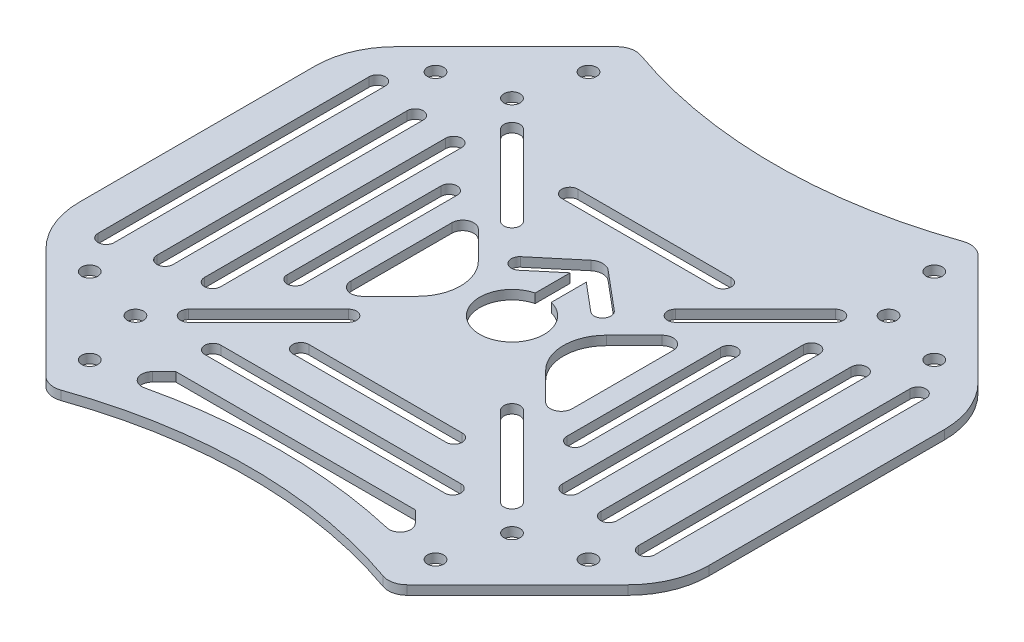
from build123d import *

# Parameters (mm, degrees)
SKETCH_1_R      = 1.5
EXTRUDE_1_DEPTH = 1.7
FILLET_1_R      = 3.5
FILLET_2_R      = 15


with BuildPart() as part:
    # 草圖1 → 填料-伸長1 (new body)
    with BuildSketch(Plane(origin=(0, 0, 0), x_dir=(1, 0, 0), z_dir=(0, 1, 0))):
        with BuildLine():
            Line((-31.988251141, -54.632329554), (-58.5, -28.120580695))
            Line((-58.5, -28.120580695), (-58.5, 28.120580695))
            Line((-58.5, 28.120580695), (-31.988251141, 54.632329554))
            ThreePointArc((-31.988251141, 54.632329554), (0, 48.75576142), (31.988251141, 54.632329554))
            Line((31.988251141, 54.632329554), (58.5, 28.120580695))
            Line((58.5, 28.120580695), (58.5, -28.120580695))
            Line((58.5, -28.120580695), (31.988251141, -54.632329554))
            ThreePointArc((31.988251141, -54.632329554), (0, -48.75576142), (-31.988251141, -54.632329554))
        make_face()
        with Locations((-35.001785669, 35.001785669)):
            Circle(SKETCH_1_R, mode=Mode.SUBTRACT)
        with Locations((35.001785669, -35.001785669)):
            Circle(SKETCH_1_R, mode=Mode.SUBTRACT)
        with Locations((-35.001785669, -35.001785669)):
            Circle(SKETCH_1_R, mode=Mode.SUBTRACT)
        with Locations((35.001785669, 35.001785669)):
            Circle(SKETCH_1_R, mode=Mode.SUBTRACT)
        with Locations((-32.138003205, -46.350849507)):
            Circle(SKETCH_1_R, mode=Mode.SUBTRACT)
        with Locations((-46.350849507, -32.138003205)):
            Circle(SKETCH_1_R, mode=Mode.SUBTRACT)
        with Locations((-32.138003205, 46.350849507)):
            Circle(SKETCH_1_R, mode=Mode.SUBTRACT)
        with Locations((-46.350849507, 32.138003205)):
            Circle(SKETCH_1_R, mode=Mode.SUBTRACT)
        with Locations((46.350849507, 32.138003205)):
            Circle(SKETCH_1_R, mode=Mode.SUBTRACT)
        with Locations((32.138003205, 46.350849507)):
            Circle(SKETCH_1_R, mode=Mode.SUBTRACT)
        with Locations((32.138003205, -46.350849507)):
            Circle(SKETCH_1_R, mode=Mode.SUBTRACT)
        with Locations((46.350849507, -32.138003205)):
            Circle(SKETCH_1_R, mode=Mode.SUBTRACT)
        with BuildLine():
            Line((-14.25, 26.5), (14.25, 26.5))
            ThreePointArc((14.25, 26.5), (15.75, 25), (14.25, 23.5))
            Line((14.25, 23.5), (-14.25, 23.5))
            ThreePointArc((-14.25, 23.5), (-15.75, 25), (-14.25, 26.5))
        make_face(mode=Mode.SUBTRACT)
        with BuildLine():
            Line((-14.25, -26.5), (14.25, -26.5))
            ThreePointArc((14.25, -26.5), (15.75, -25), (14.25, -23.5))
            Line((14.25, -23.5), (-14.25, -23.5))
            ThreePointArc((-14.25, -23.5), (-15.75, -25), (-14.25, -26.5))
        make_face(mode=Mode.SUBTRACT)
        with BuildLine():
            Line((-28.991378029, 31.112698372), (-14.142135624, 16.263455967))
            ThreePointArc((-14.142135624, 16.263455967), (-14.142135624, 14.142135624), (-16.263455967, 14.142135624))
            Line((-16.263455967, 14.142135624), (-31.112698372, 28.991378029))
            ThreePointArc((-31.112698372, 28.991378029), (-31.112698372, 31.112698372), (-28.991378029, 31.112698372))
        make_face(mode=Mode.SUBTRACT)
        with BuildLine():
            Line((28.991378029, 31.112698372), (14.142135624, 16.263455967))
            ThreePointArc((14.142135624, 16.263455967), (14.142135624, 14.142135624), (16.263455967, 14.142135624))
            Line((16.263455967, 14.142135624), (31.112698372, 28.991378029))
            ThreePointArc((31.112698372, 28.991378029), (31.112698372, 31.112698372), (28.991378029, 31.112698372))
        make_face(mode=Mode.SUBTRACT)
        with BuildLine():
            Line((28.991378029, -31.112698372), (14.142135624, -16.263455967))
            ThreePointArc((14.142135624, -16.263455967), (14.142135624, -14.142135624), (16.263455967, -14.142135624))
            Line((16.263455967, -14.142135624), (31.112698372, -28.991378029))
            ThreePointArc((31.112698372, -28.991378029), (31.112698372, -31.112698372), (28.991378029, -31.112698372))
        make_face(mode=Mode.SUBTRACT)
        with BuildLine():
            Line((-28.991378029, -31.112698372), (-14.142135624, -16.263455967))
            ThreePointArc((-14.142135624, -16.263455967), (-14.142135624, -14.142135624), (-16.263455967, -14.142135624))
            Line((-16.263455967, -14.142135624), (-31.112698372, -28.991378029))
            ThreePointArc((-31.112698372, -28.991378029), (-31.112698372, -31.112698372), (-28.991378029, -31.112698372))
        make_face(mode=Mode.SUBTRACT)
        with BuildLine():
            Line((-31.75, 22.4), (-31.75, -22.4))
            ThreePointArc((-31.75, -22.4), (-33.25, -23.9), (-34.75, -22.4))
            Line((-34.75, -22.4), (-34.75, 22.4))
            ThreePointArc((-34.75, 22.4), (-33.25, 23.9), (-31.75, 22.4))
        make_face(mode=Mode.SUBTRACT)
        with BuildLine():
            Line((-39.75, 23.25), (-39.75, -23.25))
            ThreePointArc((-39.75, -23.25), (-41.25, -24.75), (-42.75, -23.25))
            Line((-42.75, -23.25), (-42.75, 23.25))
            ThreePointArc((-42.75, 23.25), (-41.25, 24.75), (-39.75, 23.25))
        make_face(mode=Mode.SUBTRACT)
        with BuildLine():
            Line((-48.75, 25.2), (-48.75, -25.2))
            ThreePointArc((-48.75, -25.2), (-50.25, -26.7), (-51.75, -25.2))
            Line((-51.75, -25.2), (-51.75, 25.2))
            ThreePointArc((-51.75, 25.2), (-50.25, 26.7), (-48.75, 25.2))
        make_face(mode=Mode.SUBTRACT)
        with BuildLine():
            Line((48.75, 25.2), (48.75, -25.2))
            ThreePointArc((48.75, -25.2), (50.25, -26.7), (51.75, -25.2))
            Line((51.75, -25.2), (51.75, 25.2))
            ThreePointArc((51.75, 25.2), (50.25, 26.7), (48.75, 25.2))
        make_face(mode=Mode.SUBTRACT)
        with BuildLine():
            Line((39.75, 23.25), (39.75, -23.25))
            ThreePointArc((39.75, -23.25), (41.25, -24.75), (42.75, -23.25))
            Line((42.75, -23.25), (42.75, 23.25))
            ThreePointArc((42.75, 23.25), (41.25, 24.75), (39.75, 23.25))
        make_face(mode=Mode.SUBTRACT)
        with BuildLine():
            Line((31.75, 22.4), (31.75, -22.4))
            ThreePointArc((31.75, -22.4), (33.25, -23.9), (34.75, -22.4))
            Line((34.75, -22.4), (34.75, 22.4))
            ThreePointArc((34.75, 22.4), (33.25, 23.9), (31.75, 22.4))
        make_face(mode=Mode.SUBTRACT)
        with BuildLine():
            Line((-24.5, 14.3), (-24.5, -14.3))
            ThreePointArc((-24.5, -14.3), (-26, -15.8), (-27.5, -14.3))
            Line((-27.5, -14.3), (-27.5, 14.3))
            ThreePointArc((-27.5, 14.3), (-26, 15.8), (-24.5, 14.3))
        make_face(mode=Mode.SUBTRACT)
        with BuildLine():
            Line((-1.5, 5.809475019), (-1.5, 12.309475019))
            Line((-1.5, 12.309475019), (-6.701273653, 7.945088216))
            ThreePointArc((-6.701273653, 7.945088216), (-8.884963334, 8.136136308), (-8.693915243, 10.319825989))
            Line((-8.693915243, 10.319825989), (-1.606969024, 16.266479947))
            ThreePointArc((-1.606969024, 16.266479947), (0, 16.85136884), (1.606969024, 16.266479947))
            Line((1.606969024, 16.266479947), (8.693915243, 10.319825989))
            ThreePointArc((8.693915243, 10.319825989), (8.884963334, 8.136136308), (6.701273653, 7.945088216))
            Line((6.701273653, 7.945088216), (1.5, 12.309475019))
            Line((1.5, 12.309475019), (1.5, 5.809475019))
            ThreePointArc((1.5, 5.809475019), (0, -6), (-1.5, 5.809475019))
        make_face(mode=Mode.SUBTRACT)
        with BuildLine():
            Line((24.5, 14.3), (24.5, -14.3))
            ThreePointArc((24.5, -14.3), (26, -15.8), (27.5, -14.3))
            Line((27.5, -14.3), (27.5, 14.3))
            ThreePointArc((27.5, 14.3), (26, 15.8), (24.5, 14.3))
        make_face(mode=Mode.SUBTRACT)
        with BuildLine():
            Line((-22.3, -31.8), (22.3, -31.8))
            ThreePointArc((22.3, -31.8), (23.8, -33.3), (22.3, -34.8))
            Line((22.3, -34.8), (-22.3, -34.8))
            ThreePointArc((-22.3, -34.8), (-23.8, -33.3), (-22.3, -31.8))
        make_face(mode=Mode.SUBTRACT)
        with BuildLine():
            Line((20.566347785, -9.367820826), (20.566347785, 9.367820826))
            ThreePointArc((20.566347785, 9.367820826), (19.303516728, 11.257781063), (17.074156624, 10.814333767))
            Line((17.074156624, 10.814333767), (11.904413984, 5.644591127))
            ThreePointArc((11.904413984, 5.644591127), (9.566347785, 0), (11.904413984, -5.644591127))
            Line((11.904413984, -5.644591127), (17.074156624, -10.814333767))
            ThreePointArc((17.074156624, -10.814333767), (19.303516728, -11.257781063), (20.566347785, -9.367820826))
        make_face(mode=Mode.SUBTRACT)
        with BuildLine():
            Line((-17.074156624, -10.814333767), (-11.904413984, -5.644591127))
            ThreePointArc((-11.904413984, -5.644591127), (-9.566347785, 0), (-11.904413984, 5.644591127))
            Line((-11.904413984, 5.644591127), (-17.074156624, 10.814333767))
            ThreePointArc((-17.074156624, 10.814333767), (-19.303516728, 11.257781063), (-20.566347785, 9.367820826))
            Line((-20.566347785, 9.367820826), (-20.566347785, -9.367820826))
            ThreePointArc((-20.566347785, -9.367820826), (-19.303516728, -11.257781063), (-17.074156624, -10.814333767))
        make_face(mode=Mode.SUBTRACT)
        with BuildLine():
            Line((-22.261855959, -40.237571716), (22.261855959, -40.237571716))
            Line((22.261855959, -40.237571716), (24.43166791, -42.407383666))
            ThreePointArc((24.43166791, -42.407383666), (24.766340216, -44.791854009), (22.566131713, -45.770008859))
            ThreePointArc((22.566131713, -45.770008859), (11.356536667, -43.837537687), (0, -43.190590357))
            ThreePointArc((0, -43.190590357), (-11.356536667, -43.837537687), (-22.566131713, -45.770008859))
            ThreePointArc((-22.566131713, -45.770008859), (-24.766340216, -44.791854009), (-24.43166791, -42.407383666))
            Line((-24.43166791, -42.407383666), (-22.261855959, -40.237571716))
        make_face(mode=Mode.SUBTRACT)
    extrude(amount=EXTRUDE_1_DEPTH)

    # 圓角1
    fillet_1_edges = [part.edges().sort_by_distance(p)[0] for p in [
        (31.988251141, 0.85, 54.632329554),
        (-31.988251141, 0.85, 54.632329554),
        (-31.988251141, 0.85, -54.632329554),
        (31.988251141, 0.85, -54.632329554),
    ]]
    fillet(fillet_1_edges, radius=FILLET_1_R)

    # 圓角2
    fillet_2_edges = [part.edges().sort_by_distance(p)[0] for p in [
        (58.5, 0.85, -28.120580695),
        (58.5, 0.85, 28.120580695),
        (-58.5, 0.85, 28.120580695),
        (-58.5, 0.85, -28.120580695),
    ]]
    fillet(fillet_2_edges, radius=FILLET_2_R)


solid = part.part
